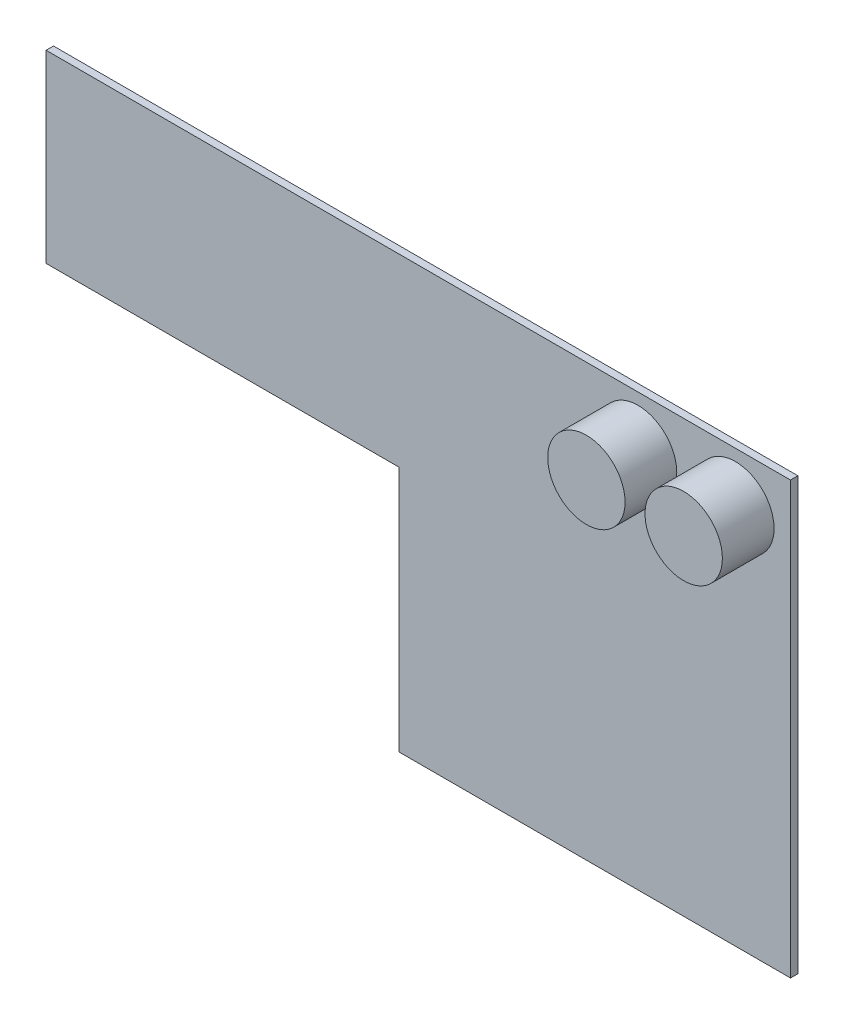
from build123d import *

# Parameters (mm, degrees)
BOSS_EXTRUDE1_DEPTH = 5
SKETCH2_R           = 26.19375
BOSS_EXTRUDE2_DEPTH = 35


with BuildPart() as part:
    # Sketch1 → Boss-Extrude1 (new body)
    with BuildSketch(Plane.XY):
        Polygon((0, 0), (265, 0), (265, 292), (-239, 292), (-239, 167), (0, 167), align=None)
    extrude(amount=BOSS_EXTRUDE1_DEPTH)

    # Sketch2 → Boss-Extrude2 (add)
    with BuildSketch(Plane.XY.offset(5)):
        with Locations((227.686407853, 257.993451028)):
            Circle(SKETCH2_R)
        with Locations((161.807907248, 257.993451028)):
            Circle(SKETCH2_R)
    extrude(amount=BOSS_EXTRUDE2_DEPTH)


solid = part.part
